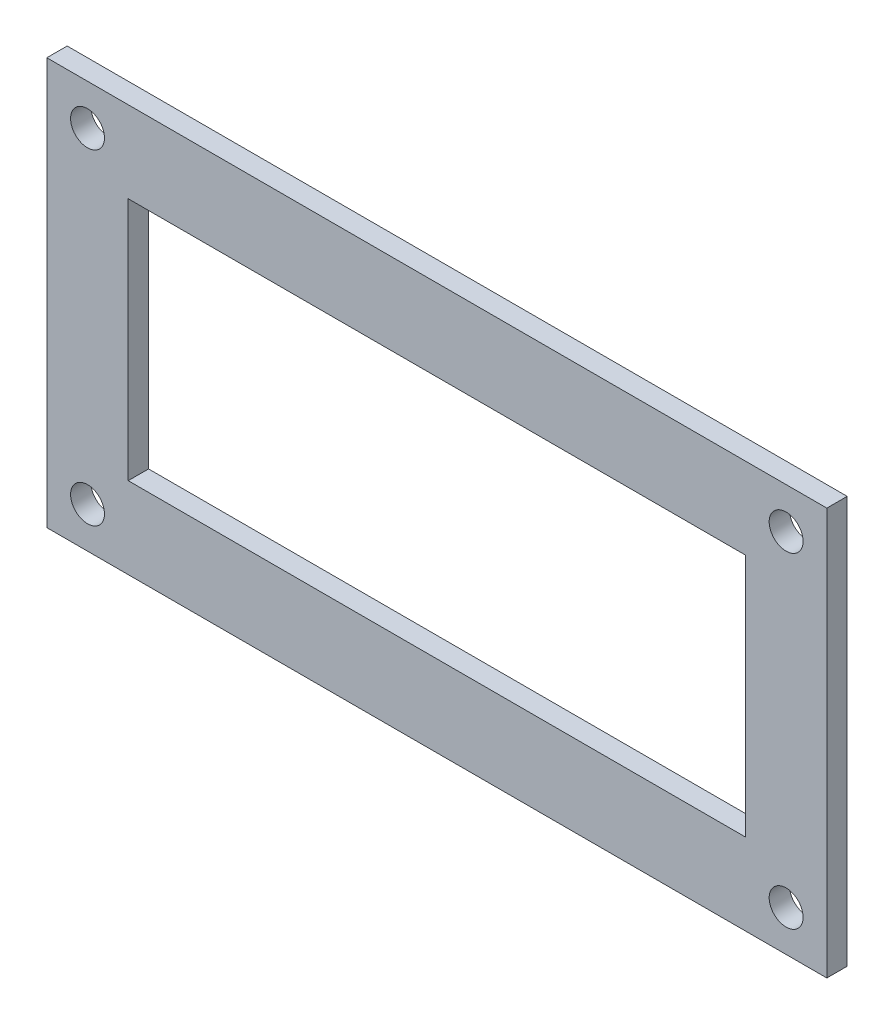
from build123d import *

# Parameters (mm, degrees)
SKETCH1_W           = 115
SKETCH1_H           = 60
SKETCH1_R           = 2.5
SKETCH1_W_2         = 91
SKETCH1_H_2         = 36
BOSS_EXTRUDE1_DEPTH = 3


with BuildPart() as part:
    # Sketch1 → Boss-Extrude1 (new body)
    with BuildSketch(Plane.XY):
        with Locations((57.5, 30)):
            Rectangle(SKETCH1_W, SKETCH1_H)
        with Locations((6, 6)):
            Circle(SKETCH1_R, mode=Mode.SUBTRACT)
        with Locations((6, 54)):
            Circle(SKETCH1_R, mode=Mode.SUBTRACT)
        with Locations((109, 54)):
            Circle(SKETCH1_R, mode=Mode.SUBTRACT)
        with Locations((109, 6)):
            Circle(SKETCH1_R, mode=Mode.SUBTRACT)
        with Locations((57.5, 30)):
            Rectangle(SKETCH1_W_2, SKETCH1_H_2, mode=Mode.SUBTRACT)
    extrude(amount=BOSS_EXTRUDE1_DEPTH)


solid = part.part
